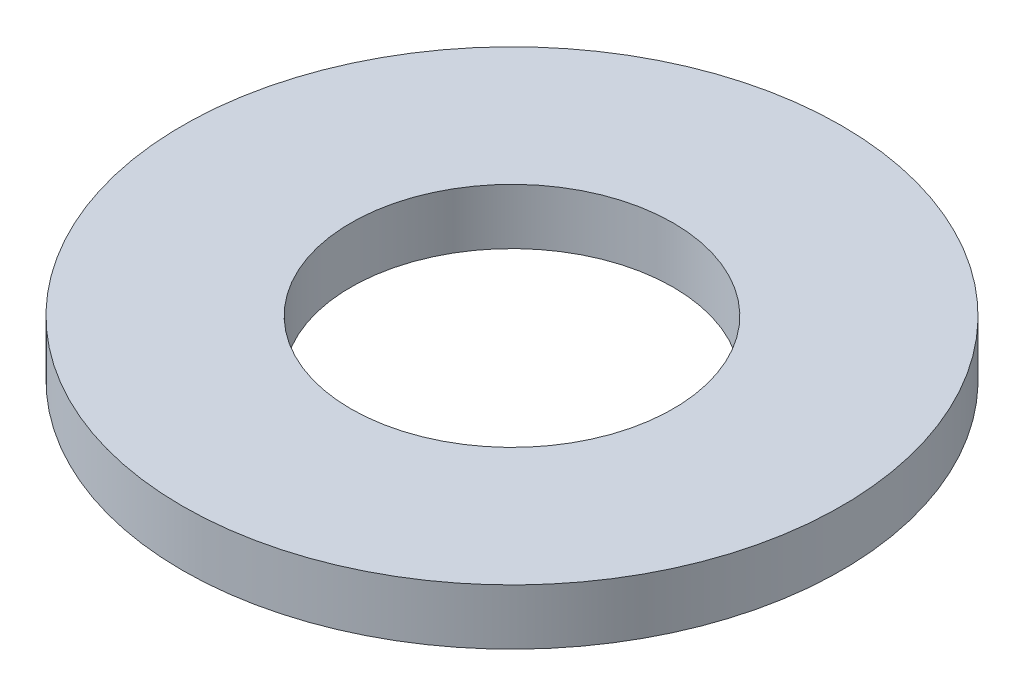
from build123d import *

# Parameters (mm, degrees)
SKETCH2_R           = 4.5
SKETCH2_R_2         = 2.2
BOSS_EXTRUDE1_DEPTH = 0.76


with BuildPart() as part:
    # Sketch2 → Boss-Extrude1 (new body)
    with BuildSketch(Plane(origin=(0, 0, 0), x_dir=(1, 0, 0), z_dir=(0, 1, 0))):
        Circle(SKETCH2_R)
        Circle(SKETCH2_R_2, mode=Mode.SUBTRACT)
    extrude(amount=BOSS_EXTRUDE1_DEPTH)


solid = part.part
